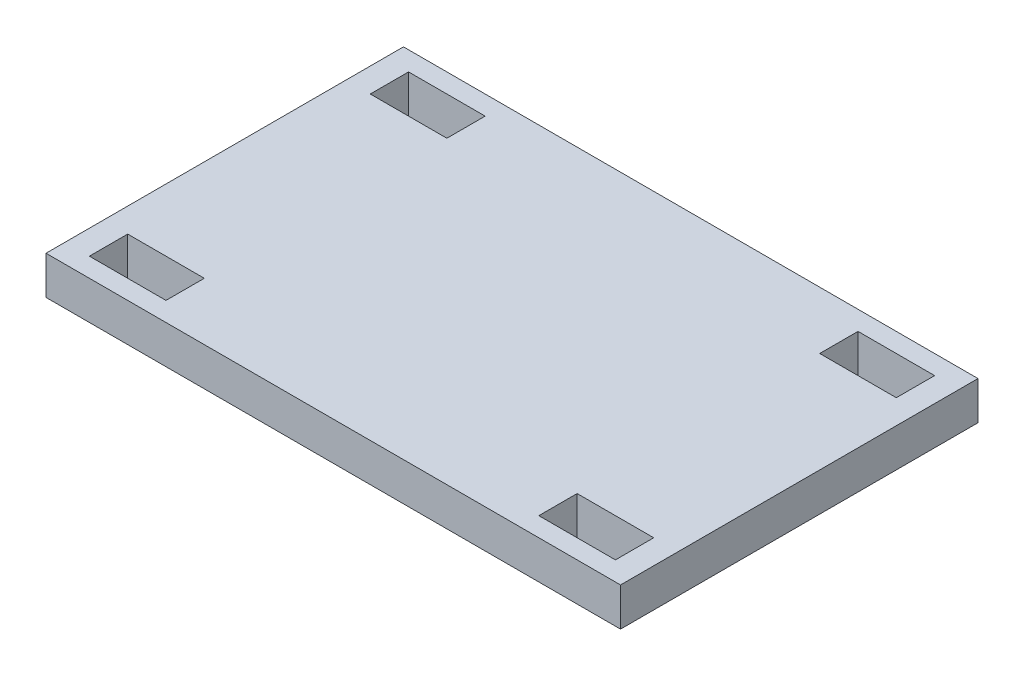
from build123d import *

# Parameters (mm, degrees)
SKETCH_1_W          = 45
SKETCH_1_H          = 28
EXTRUDE_1_DEPTH     = 3
SKETCH_2_W          = 6
SKETCH_2_H          = 3
CUT_EXTRUDE_1_DEPTH = 4


with BuildPart() as part:
    # 스케치1 → 보스-돌출1 (new body)
    with BuildSketch(Plane(origin=(0, 0, 0), x_dir=(1, 0, 0), z_dir=(0, 1, 0))):
        with Locations((22.5, 14)):
            Rectangle(SKETCH_1_W, SKETCH_1_H)
    extrude(amount=EXTRUDE_1_DEPTH)

    # 스케치2 → 컷-돌출1 (cut, through all)
    with BuildSketch(Plane(origin=(0, 3, 0), x_dir=(1, 0, 0), z_dir=(0, 1, 0))):
        with Locations((4.898604001, 25)):
            Rectangle(SKETCH_2_W, SKETCH_2_H)
        with Locations((4.898604001, 3)):
            Rectangle(SKETCH_2_W, SKETCH_2_H)
        with Locations((40.101395999, 3)):
            Rectangle(SKETCH_2_W, SKETCH_2_H)
        with Locations((40.101395999, 25)):
            Rectangle(SKETCH_2_W, SKETCH_2_H)
    extrude(amount=-CUT_EXTRUDE_1_DEPTH, mode=Mode.SUBTRACT)


solid = part.part
